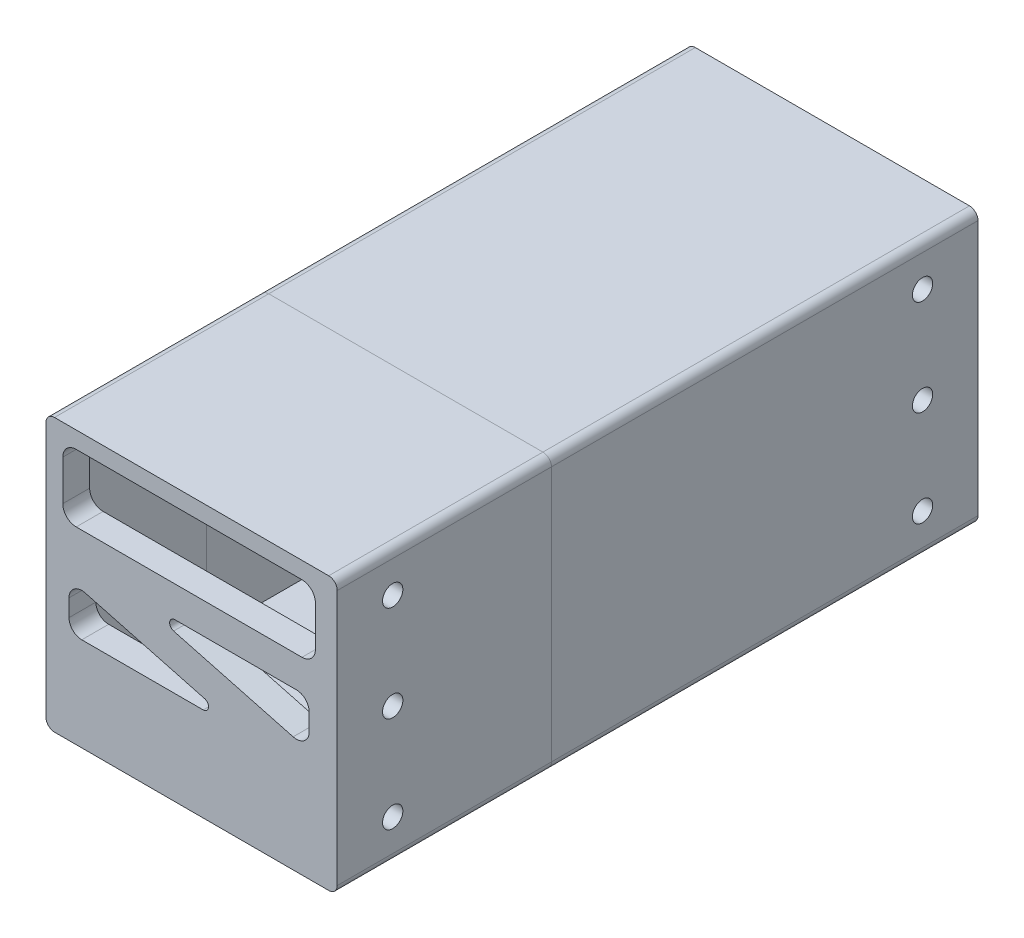
from build123d import *

# Parameters (mm, degrees)
SKETCH1_W            = 85.216
SKETCH1_H            = 81.152
BOSS_EXTRUDE1_DEPTH  = 182.776
SHELL2_T             = -4
SHELL3_T             = -4
SKETCH4_W            = 81.216
SKETCH4_H            = 77.152
SKETCH4_W_2          = 77.216
SKETCH4_H_2          = 73.152
BOSS_EXTRUDE2_DEPTH  = 20
SKETCH5_W            = 81.978
SKETCH5_H            = 77.914
SKETCH5_W_2          = 77.216
SKETCH5_H_2          = 73.152
CUT_EXTRUDE2_DEPTH   = 20
SKETCH6_W            = 75.216
SKETCH6_H            = 20
CUT_EXTRUDE3_DEPTH   = 4
FILLET3_R            = 4
SKETCH7_W            = 85.216
SKETCH7_H            = 81.152
BOSS_EXTRUDE3_DEPTH  = 4
SKETCH8_W            = 85.216
SKETCH8_H            = 81.152
BOSS_EXTRUDE4_DEPTH  = 4
SKETCH9_R            = 3.025
CUT_EXTRUDE4_DEPTH   = 6
SKETCH10_W           = 77.216
SKETCH10_H           = 73.152
BOSS_EXTRUDE5_DEPTH  = 4.500000096
CUT_EXTRUDE5_DEPTH   = 12.5
CUT_EXTRUDE6_DEPTH   = 8
SKETCH13_W           = 59.776
SKETCH13_H           = 81.152
BOSS_EXTRUDE7_DEPTH  = 1.5
SKETCH15_W           = 131
SKETCH15_H           = 81.152
BOSS_EXTRUDE8_DEPTH  = 1.5
FILLET4_R            = 2.54
FILLET5_R            = 2.54
SKETCH16_R           = 3.025
CUT_EXTRUDE9_DEPTH   = 19.5
SKETCH18_W           = 62.209478129
SKETCH18_H           = 16.943734599
BOSS_EXTRUDE9_DEPTH  = 8
SKETCH19_W           = 60.72535539
SKETCH19_H           = 14.841227386
BOSS_EXTRUDE10_DEPTH = 12.5
SKETCH20_W           = 81.216
SKETCH20_H           = 77.152
SKETCH20_W_2         = 77.216
SKETCH20_H_2         = 73.152
BOSS_EXTRUDE11_DEPTH = 20
SKETCH21_W           = 81.216
SKETCH21_H           = 77.152
CUT_EXTRUDE10_DEPTH  = 20


with BuildPart() as part:
    # Sketch1 → Boss-Extrude1 (new body)
    with BuildSketch(Plane.XY):
        Rectangle(SKETCH1_W, SKETCH1_H)
    extrude(amount=BOSS_EXTRUDE1_DEPTH)


with BuildPart() as body_2:
    # Split1: the piece on the far side of the plane
    add(part.part)
    split(bisect_by=Plane(origin=(0, 0, 127), x_dir=(-1, 0, 0), z_dir=(0, 0, -1)), keep=Keep.BOTTOM)

    # Shell3
    shell3_openings = [body_2.faces().sort_by_distance(p)[0] for p in [
        (0, 0, 127),
    ]]
    offset(amount=SHELL3_T, openings=shell3_openings, kind=Kind.INTERSECTION)

    # Sketch5 → Cut-Extrude2 (cut)
    with BuildSketch(Plane(origin=(0, 0, 127), x_dir=(-1, 0, 0), z_dir=(0, 0, -1))):
        Rectangle(SKETCH5_W, SKETCH5_H)
        Rectangle(SKETCH5_W_2, SKETCH5_H_2, mode=Mode.SUBTRACT)
    extrude(amount=-CUT_EXTRUDE2_DEPTH, mode=Mode.SUBTRACT)

    # Sketch6 → Cut-Extrude3 (cut)
    with BuildSketch(Plane.XY.offset(182.776)):
        with Locations((0, 25.576)):
            Rectangle(SKETCH6_W, SKETCH6_H)
    extrude(amount=-CUT_EXTRUDE3_DEPTH, mode=Mode.SUBTRACT)

    # Fillet3
    fillet3_edges = [body_2.edges().sort_by_distance(p)[0] for p in [
        (37.608, 35.576, 180.776),
        (37.608, 15.576, 180.776),
        (-37.608, 15.576, 180.776),
        (-37.608, 35.576, 180.776),
    ]]
    fillet(fillet3_edges, radius=FILLET3_R)

    # Sketch7 → Boss-Extrude3 (add)
    with BuildSketch(Plane.XY.offset(182.776)):
        Rectangle(SKETCH7_W, SKETCH7_H)
        with BuildLine():
            Line((-33.608, 15.576), (33.608, 15.576))
            ThreePointArc((33.608, 15.576), (36.436427125, 16.747572875), (37.608, 19.576))
            Line((37.608, 19.576), (37.608, 31.576))
            ThreePointArc((37.608, 31.576), (36.436427125, 34.404427125), (33.608, 35.576))
            Line((33.608, 35.576), (-33.608, 35.576))
            ThreePointArc((-33.608, 35.576), (-36.436427125, 34.404427125), (-37.608, 31.576))
            Line((-37.608, 31.576), (-37.608, 19.576))
            ThreePointArc((-37.608, 19.576), (-36.436427125, 16.747572875), (-33.608, 15.576))
        make_face(mode=Mode.SUBTRACT)
    extrude(amount=BOSS_EXTRUDE3_DEPTH)

    # Sketch9 → Cut-Extrude4 (cut)
    with BuildSketch(Plane.XY.offset(186.776)):
        with Locations((-21.304, -27.876)):
            Circle(SKETCH9_R)
        with Locations((0, -27.876)):
            Circle(SKETCH9_R)
        with Locations((21.304, -27.876)):
            Circle(SKETCH9_R)
    cut_extrude4 = extrude(amount=-CUT_EXTRUDE4_DEPTH, mode=Mode.SUBTRACT)

    # Sketch12 → Cut-Extrude6 (cut)
    with BuildSketch(Plane.XY.offset(186.776)):
        with BuildLine():
            Line((-30.972571902, -0.100195505), (4.615140384, -9.578475727))
            ThreePointArc((4.615140384, -9.578475727), (5.780649168, -11.318525139), (4.206574871, -12.7))
            Line((4.206574871, -12.7), (-31.953129133, -12.7))
            ThreePointArc((-31.953129133, -12.7), (-34.64720597, -11.584076836), (-35.763129133, -8.89))
            Line((-35.763129133, -8.89), (-35.763129133, -3.781853761))
            ThreePointArc((-35.763129133, -3.781853761), (-34.274785541, -0.760924844), (-30.972571902, -0.100195505))
        make_face()
        with BuildLine():
            Line((-4.206574871, 6.35), (31.953129133, 6.35))
            ThreePointArc((31.953129133, 6.35), (34.64720597, 5.234076836), (35.763129133, 2.54))
            Line((35.763129133, 2.54), (35.763129133, -2.568146239))
            ThreePointArc((35.763129133, -2.568146239), (34.274785541, -5.589075156), (30.972571902, -6.249804495))
            Line((30.972571902, -6.249804495), (-4.615140384, 3.228475727))
            ThreePointArc((-4.615140384, 3.228475727), (-5.780649168, 4.968525139), (-4.206574871, 6.35))
        make_face()
    extrude(amount=-CUT_EXTRUDE6_DEPTH, mode=Mode.SUBTRACT)


with BuildPart() as part_1:
    add(part.part)

    # Split1
    split(bisect_by=Plane(origin=(0, 0, 127), x_dir=(-1, 0, 0), z_dir=(0, 0, -1)), keep=Keep.TOP)

    # Shell2
    shell2_openings = [part_1.faces().sort_by_distance(p)[0] for p in [
        (0, 0, 127),
    ]]
    offset(amount=SHELL2_T, openings=shell2_openings, kind=Kind.INTERSECTION)

    # Sketch4 → Boss-Extrude2 (add)
    with BuildSketch(Plane.XY.offset(127)):
        Rectangle(SKETCH4_W, SKETCH4_H)
        Rectangle(SKETCH4_W_2, SKETCH4_H_2, mode=Mode.SUBTRACT)
    extrude(amount=BOSS_EXTRUDE2_DEPTH)

    # Sketch8 → Boss-Extrude4 (add)
    with BuildSketch(Plane(origin=(0, 0, 0), x_dir=(-1, 0, 0), z_dir=(0, 0, -1))):
        Rectangle(SKETCH8_W, SKETCH8_H)
    extrude(amount=BOSS_EXTRUDE4_DEPTH)

    # Mirror1: Cut-Extrude4 across plane
    add(cut_extrude4.mirror(Plane.XY.offset(91.388)), mode=Mode.SUBTRACT)

    # Sketch10 → Boss-Extrude5 (add)
    with BuildSketch(Plane.XY.offset(4)):
        Rectangle(SKETCH10_W, SKETCH10_H)
    extrude(amount=BOSS_EXTRUDE5_DEPTH)

    # Sketch11 → Cut-Extrude5 (cut)
    with BuildSketch(Plane(origin=(0, 0, -4), x_dir=(-1, 0, 0), z_dir=(0, 0, -1))):
        with BuildLine():
            ThreePointArc((29.908, 24.066), (28.792076836, 26.760076836), (26.098, 27.876))
            Line((26.098, 27.876), (11.727473696, 27.876))
            ThreePointArc((11.727473696, 27.876), (8.103904131, 25.243218589), (9.488243538, 20.983476959))
            Line((9.488243538, 20.983476959), (23.858769841, 10.544328421))
            ThreePointArc((23.858769841, 10.544328421), (27.827831364, 10.232181603), (29.908, 13.626851462))
            Line((29.908, 13.626851462), (29.908, 24.066))
        make_face()
        with BuildLine():
            ThreePointArc((-23.858769841, 1.819526927), (-27.827831364, 2.131673746), (-29.908, -1.262996113))
            Line((-29.908, -1.262996113), (-29.908, -11.766))
            ThreePointArc((-29.908, -11.766), (-28.792076836, -14.460076836), (-26.098, -15.576))
            Line((-26.098, -15.576), (-11.639570458, -15.576))
            ThreePointArc((-11.639570458, -15.576), (-8.016000893, -12.943218589), (-9.400340299, -8.683476959))
            Line((-9.400340299, -8.683476959), (-23.858769841, 1.819526927))
        make_face()
        with BuildLine():
            ThreePointArc((22.443899471, -18.002473668), (31.313488137, -16.596985531), (29.908, -7.727396865))
            Line((29.908, -7.727396865), (-22.443899471, 30.302473668))
            ThreePointArc((-22.443899471, 30.302473668), (-31.313488137, 28.896985531), (-29.908, 20.027396865))
            Line((-29.908, 20.027396865), (22.443899471, -18.002473668))
        make_face()
    extrude(amount=-CUT_EXTRUDE5_DEPTH, mode=Mode.SUBTRACT)

    add(body_2.part)  # Boss-Extrude7 merges body 2
    # Sketch13 → Boss-Extrude7 (add)
    with BuildSketch(Plane.ZY.offset(-42.608)):
        with Locations((156.888, 0)):
            Rectangle(SKETCH13_W, SKETCH13_H)
    extrude(amount=-BOSS_EXTRUDE7_DEPTH)

    # Sketch15 → Boss-Extrude8 (add)
    with BuildSketch(Plane(origin=(42.608, 0, 0), x_dir=(0, 0, -1), z_dir=(1, 0, 0))):
        with Locations((-61.5, 0)):
            Rectangle(SKETCH15_W, SKETCH15_H)
    extrude(amount=BOSS_EXTRUDE8_DEPTH)


with BuildPart() as body_2_2:
    # Split2: the piece on the far side of the plane
    add(part_1.part)
    split(bisect_by=Plane(origin=(0, 0, 123), x_dir=(-1, 0, 0), z_dir=(0, 0, -1)), keep=Keep.BOTTOM)

    # Fillet4
    fillet4_edges = [body_2_2.edges().sort_by_distance(p)[0] for p in [
        (44.108, -40.576, 154.888),
        (44.108, 40.576, 154.888),
        (-42.608, 40.576, 154.888),
        (-42.608, -40.576, 154.888),
    ]]
    fillet(fillet4_edges, radius=FILLET4_R)


with BuildPart() as part_2:
    add(part_1.part)

    # Split2
    split(bisect_by=Plane(origin=(0, 0, 123), x_dir=(-1, 0, 0), z_dir=(0, 0, -1)), keep=Keep.TOP)

    # Fillet5
    fillet5_edges = [part_2.edges().sort_by_distance(p)[0] for p in [
        (44.108, -40.576, 59.5),
        (44.108, 40.576, 59.5),
        (-42.608, 40.576, 59.5),
        (-42.608, -40.576, 59.5),
    ]]
    fillet(fillet5_edges, radius=FILLET5_R)


with BuildPart() as cut_extrude9_tool:
    # Sketch16 → Cut-Extrude9 (new body)
    with BuildSketch(Plane(origin=(44.108, 0, 0), x_dir=(0, 0, -1), z_dir=(1, 0, 0))):
        with Locations((-170.266, 28.575)):
            Circle(SKETCH16_R)
        with Locations((-170.266, 0)):
            Circle(SKETCH16_R)
        with Locations((-170.266, -28.575)):
            Circle(SKETCH16_R)
        with Locations((-12.51, 28.575)):
            Circle(SKETCH16_R)
        with Locations((-12.51, 0)):
            Circle(SKETCH16_R)
        with Locations((-12.51, -28.575)):
            Circle(SKETCH16_R)
    extrude(amount=-CUT_EXTRUDE9_DEPTH)


with BuildPart() as part_3:
    add(part_2.part)

    # Cut-Extrude9: cut by cut_extrude9_tool
    add(cut_extrude9_tool.part, mode=Mode.SUBTRACT)

    # Sketch19 → Boss-Extrude10 (add)
    with BuildSketch(Plane(origin=(0, 0, -4), x_dir=(-1, 0, 0), z_dir=(0, 0, -1))):
        with Locations((-1.053899817, -28.260170482)):
            Rectangle(SKETCH19_W, SKETCH19_H)
    extrude(amount=-BOSS_EXTRUDE10_DEPTH)

    # Sketch20 → Boss-Extrude11 (add)
    with BuildSketch(Plane.XY.offset(123)):
        Rectangle(SKETCH20_W, SKETCH20_H)
        Rectangle(SKETCH20_W_2, SKETCH20_H_2, mode=Mode.SUBTRACT)
    extrude(amount=BOSS_EXTRUDE11_DEPTH)


with BuildPart() as body_2_2_1:
    add(body_2_2.part)

    # Cut-Extrude9: cut by cut_extrude9_tool
    add(cut_extrude9_tool.part, mode=Mode.SUBTRACT)

    # Sketch18 → Boss-Extrude9 (add)
    with BuildSketch(Plane.XY.offset(186.776)):
        with Locations((0.188161552, -26.961563086)):
            Rectangle(SKETCH18_W, SKETCH18_H)
    extrude(amount=-BOSS_EXTRUDE9_DEPTH)

    # Sketch21 → Cut-Extrude10 (cut)
    with BuildSketch(Plane(origin=(0, 0, 123), x_dir=(-1, 0, 0), z_dir=(0, 0, -1))):
        Rectangle(SKETCH21_W, SKETCH21_H)
    extrude(amount=-CUT_EXTRUDE10_DEPTH, mode=Mode.SUBTRACT)


solid = Compound([part_3.part, body_2_2_1.part])
